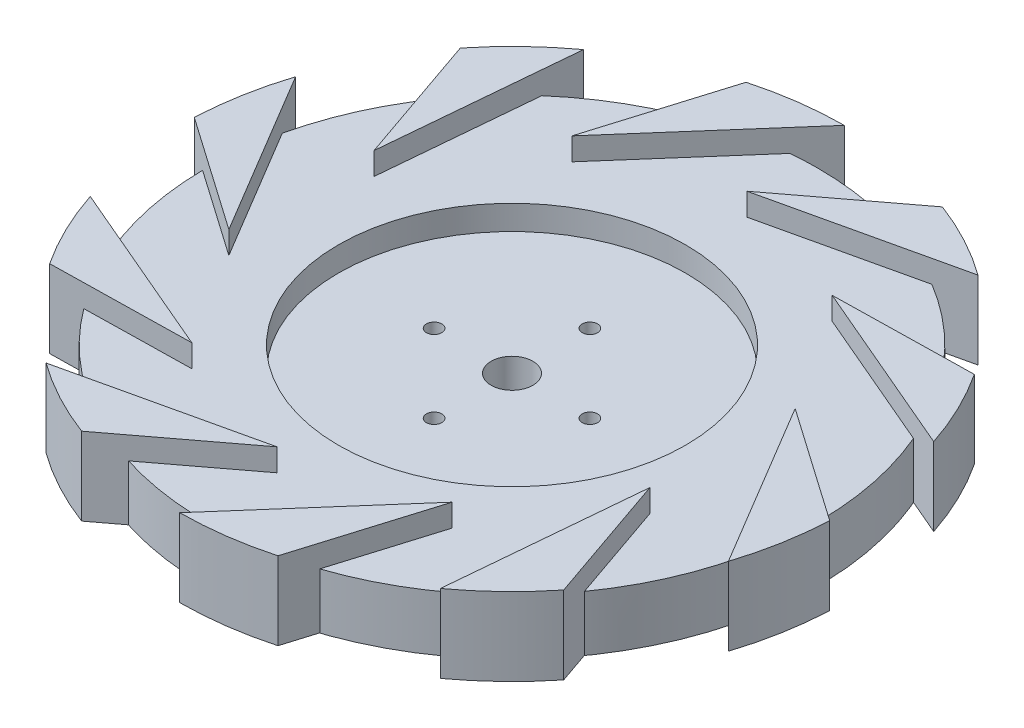
from build123d import *

# Parameters (mm, degrees)
GUIDE_START        = 3.429
GUIDE_VANES_DEPTH  = 17.78
CIRPATTERN4_COUNT  = 10
SKETCH6_R          = 1.7526
CUT_EXTRUDE1_DEPTH = 13.97
CIRPATTERN5_COUNT  = 4
SKETCH9_R          = 4.7625
CUT_EXTRUDE2_DEPTH = 7.62


with BuildPart() as part:
    # Sketch3 → Body (revolve)
    with BuildSketch(Plane.XY):
        Polygon((-69.85, 16.0734375), (-39.624, 16.0734375), (-39.624, 10.4854375), (0, 10.4854375), (0, 3.3734375), (-69.85, 3.3734375), align=None)
    revolve(axis=Axis((0, 0, 0), (0, 1, 0)))

    # Sketch4 → Guide Vanes (add)
    with BuildSketch(Plane(origin=(0, 0, 0), x_dir=(1, 0, 0), z_dir=(0, 1, 0)).offset(GUIDE_START)):
        with BuildLine():
            Line((1.553349961, 52.076946284), (26.95018459, 71.275013508))
            ThreePointArc((26.95018459, 71.275013508), (36.029244063, 67.144125374), (44.490941148, 61.862720242))
            Line((44.490941148, 61.862720242), (1.553349961, 52.076946284))
        make_face()
    guide_vanes = extrude(amount=GUIDE_VANES_DEPTH)

    # CirPattern4: Guide Vanes ×10 about axis
    cirpattern4_axis = Axis((0, 0, 0), (0, 1, 0))
    for i in range(1, CIRPATTERN4_COUNT):
        add(guide_vanes.rotate(cirpattern4_axis, i * 360 / CIRPATTERN4_COUNT))

    # Sketch6 → Cut-Extrude1 (cut)
    with BuildSketch(Plane(origin=(0, 0, 0), x_dir=(1, 0, 0), z_dir=(0, 1, 0))):
        with Locations((0, 17.78)):
            Circle(SKETCH6_R)
    cut_extrude1 = extrude(amount=CUT_EXTRUDE1_DEPTH, mode=Mode.SUBTRACT)

    # CirPattern5: Cut-Extrude1 ×4 about axis
    cirpattern5_axis = Axis((0, 0, 0), (0, 1, 0))
    for i in range(1, CIRPATTERN5_COUNT):
        add(cut_extrude1.rotate(cirpattern5_axis, i * 360 / CIRPATTERN5_COUNT), mode=Mode.SUBTRACT)

    # Sketch9 → Cut-Extrude2 (cut)
    with BuildSketch(Plane(origin=(0, 10.4854375, 0), x_dir=(1, 0, 0), z_dir=(0, 1, 0))):
        Circle(SKETCH9_R)
    extrude(amount=-CUT_EXTRUDE2_DEPTH, mode=Mode.SUBTRACT)


solid = part.part
